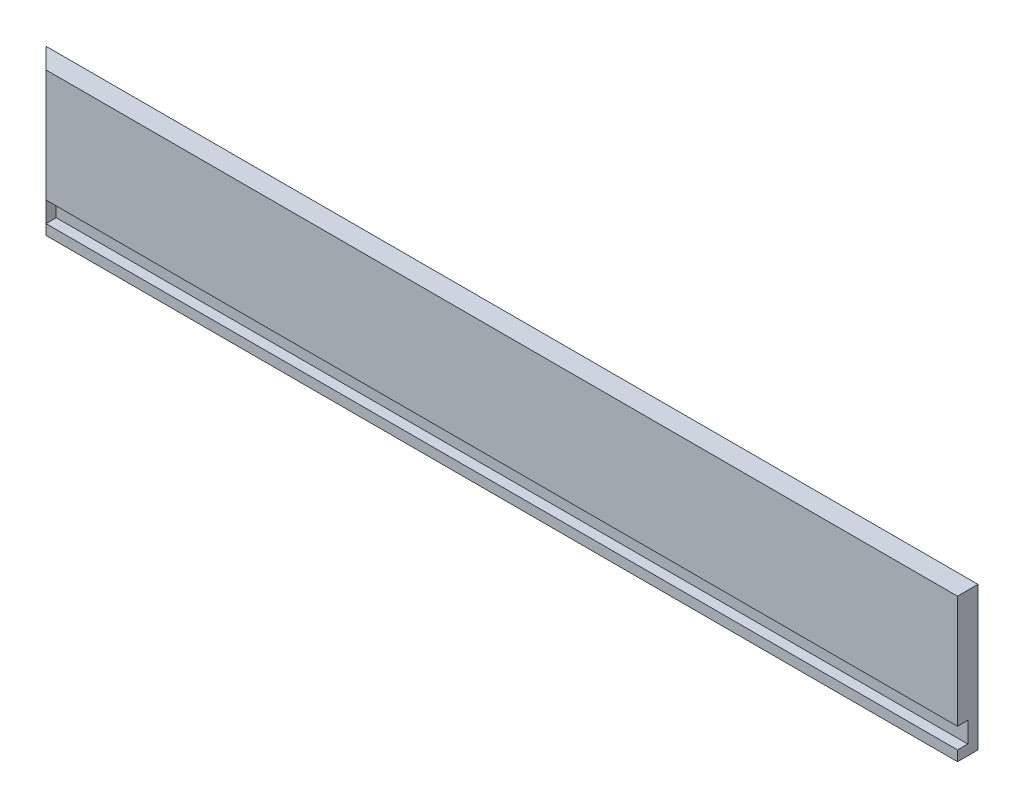
from build123d import *

# Parameters (mm, degrees)
SKETCH1_W           = 577.85
SKETCH1_H           = 88.9
BOSS_EXTRUDE1_DEPTH = 12.7
CUT_EXTRUDE1_DEPTH  = 89.9
SKETCH4_W           = 565.15
SKETCH4_H           = 12.7
CUT_EXTRUDE3_DEPTH  = 6.35


with BuildPart() as part:
    # Sketch1 → Boss-Extrude1 (new body)
    with BuildSketch(Plane.XY):
        with Locations((75.280996393, 74.68264202)):
            Rectangle(SKETCH1_W, SKETCH1_H)
    extrude(amount=BOSS_EXTRUDE1_DEPTH)

    # Sketch2 → Cut-Extrude1 (cut, through all)
    with BuildSketch(Plane(origin=(0, 119.13264202, 0), x_dir=(1, 0, 0), z_dir=(0, 1, 0))):
        Polygon((-200.944003607, -12.7), (-213.644003607, 0), (-213.644003607, -12.7), align=None)
    extrude(amount=-CUT_EXTRUDE1_DEPTH, mode=Mode.SUBTRACT)

    # Sketch4 → Cut-Extrude3 (cut)
    with BuildSketch(Plane.XY.offset(12.7)):
        with Locations((81.630996393, 42.93264202)):
            Rectangle(SKETCH4_W, SKETCH4_H)
    extrude(amount=-CUT_EXTRUDE3_DEPTH, mode=Mode.SUBTRACT)


solid = part.part
